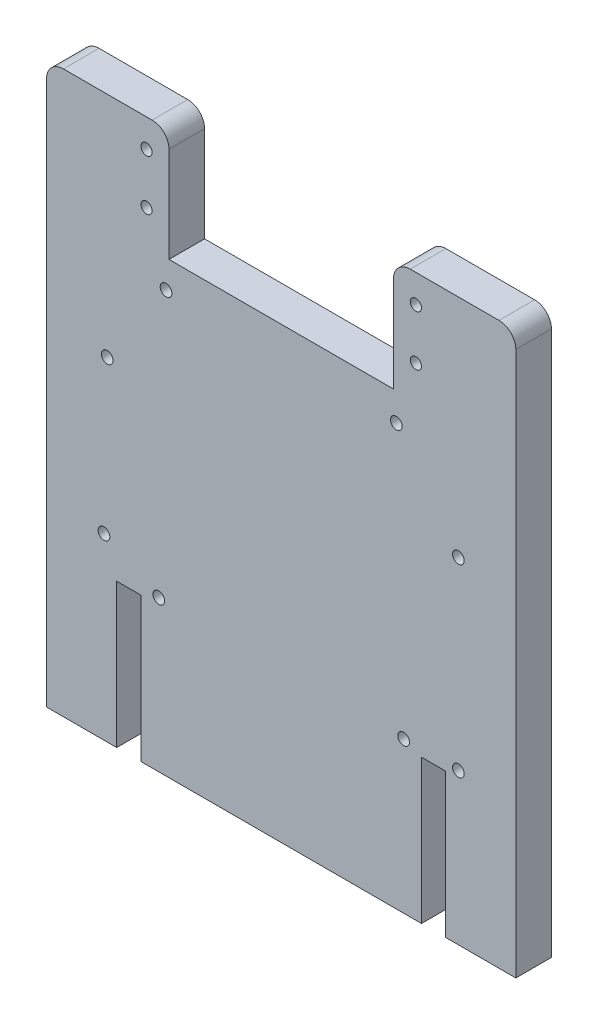
from build123d import *

# Parameters (mm, degrees)
MAIN_SHAPE_DEPTH                            = 6.35
FILLET1_R                                   = 3
F_3_48_TAPPED_HOLE1_D                       = 1.9939
F_3_48_TAPPED_HOLE1_DEPTH                   = 6.61
F_3_48_TAPPED_HOLE1_TIP                     = 0.599027994
F_3_48_TAPPED_HOLE1_FOR_ARDUINO_MOUNT_D     = 2.0828
F_3_48_TAPPED_HOLE1_FOR_ARDUINO_MOUNT_DEPTH = 7.3
F_3_48_TAPPED_HOLE1_FOR_ARDUINO_MOUNT_TIP   = 0.625736249


with BuildPart() as part:
    # Sketch1 → main shape (new body)
    with BuildSketch(Plane.XY):
        Polygon((0, 0), (0, 100), (21.818, 100), (21.818, 80), (61.818, 80), (61.818, 100), (83.636, 100), (83.636, 0), (71.136, 0), (71.136, 25.68), (66.818, 25.68), (66.818, 0), (16.818, 0), (16.818, 25.68), (12.5, 25.68), (12.5, 0), align=None)
    extrude(amount=MAIN_SHAPE_DEPTH)

    # Fillet1
    fillet1_edges = [part.edges().sort_by_distance(p)[0] for p in [
        (0, 100, 3.175),
        (21.818, 100, 3.175),
        (61.818, 100, 3.175),
        (83.636, 100, 3.175),
    ]]
    fillet(fillet1_edges, radius=FILLET1_R)

    # #3-48 Tapped Hole1
    with Locations(Plane.XY.offset(6.35)):
        with Locations((17.818, 95), (17.818, 86), (65.818, 86), (65.818, 95)):
            Hole(F_3_48_TAPPED_HOLE1_D / 2, depth=F_3_48_TAPPED_HOLE1_DEPTH)
            with Locations((0, 0, -(F_3_48_TAPPED_HOLE1_DEPTH + F_3_48_TAPPED_HOLE1_TIP / 2))):  # 118° drill point
                Cone(0, F_3_48_TAPPED_HOLE1_D / 2, F_3_48_TAPPED_HOLE1_TIP, mode=Mode.SUBTRACT)

    # #3-48 Tapped Hole1 for arduino mount
    with Locations(Plane.XY.offset(6.35)):
        with Locations((21.3, 75), (20, 26.9), (73.4, 26.9), (73.4, 59.8), (10.236, 31.9), (63.636, 26.9), (62.336, 75), (10.811692828, 59.393923536)):
            Hole(F_3_48_TAPPED_HOLE1_FOR_ARDUINO_MOUNT_D / 2, depth=F_3_48_TAPPED_HOLE1_FOR_ARDUINO_MOUNT_DEPTH)
            with Locations((0, 0, -(F_3_48_TAPPED_HOLE1_FOR_ARDUINO_MOUNT_DEPTH + F_3_48_TAPPED_HOLE1_FOR_ARDUINO_MOUNT_TIP / 2))):  # 118° drill point
                Cone(0, F_3_48_TAPPED_HOLE1_FOR_ARDUINO_MOUNT_D / 2, F_3_48_TAPPED_HOLE1_FOR_ARDUINO_MOUNT_TIP, mode=Mode.SUBTRACT)


solid = part.part
